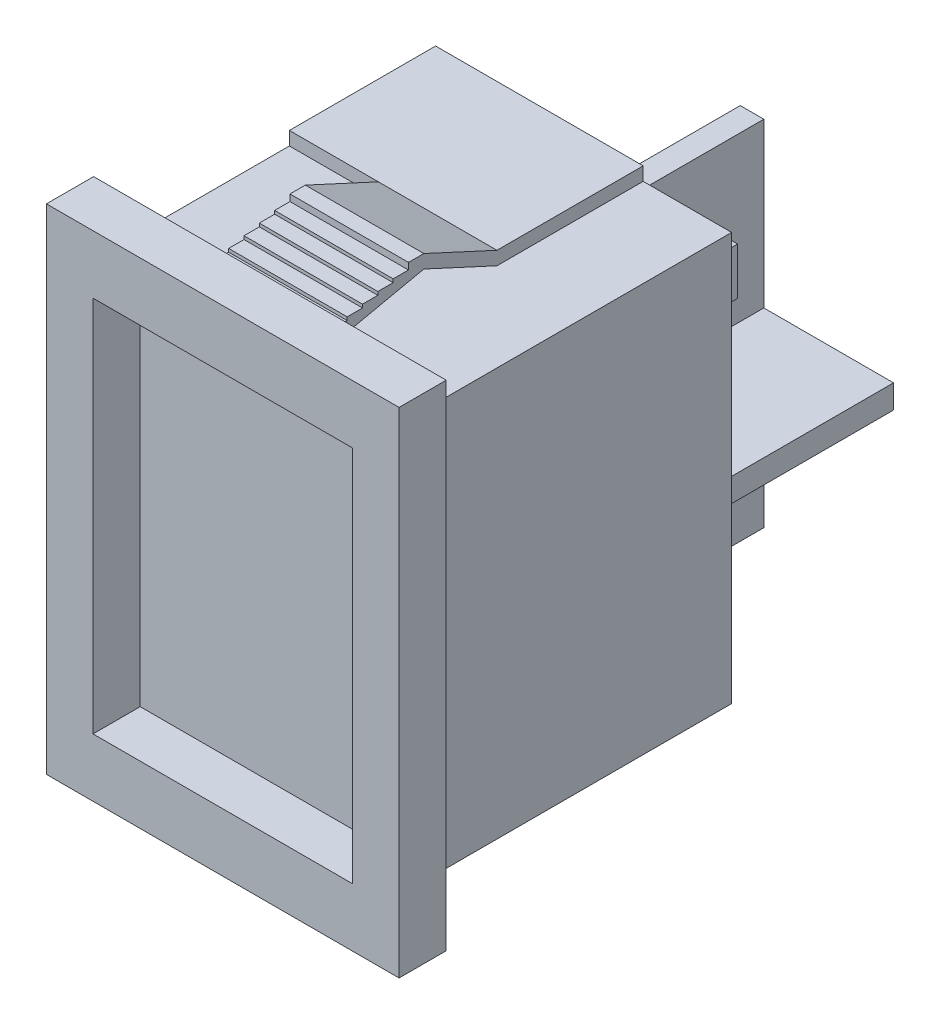
from build123d import *

# Parameters (mm, degrees)
SKETCH1_W                = 14.95
SKETCH1_H                = 20.95
SKETCH1_W_2              = 11
SKETCH1_H_2              = 16
BOSS_EXTRUDE1_DEPTH      = 2
SKETCH2_W                = 12.55
SKETCH2_H                = 17.3
BOSS_EXTRUDE2_DEPTH      = 13.3
SKETCH3_W                = 6.2
SKETCH3_H                = 18.44
BOSS_EXTRUDE3_DEPTH      = 8.8
BOSS_EXTRUDE4_DEPTH      = 2.525
BOSS_EXTRUDE4_DEPTH_BACK = 2.5
BOSS_EXTRUDE5_DEPTH      = 7.14
SKETCH6_W                = 2.5
SKETCH6_H                = 2
BOSS_EXTRUDE6_DEPTH      = 1


with BuildPart() as part:
    # Sketch1 → Boss-Extrude1 (new body)
    with BuildSketch(Plane.XY):
        Rectangle(SKETCH1_W, SKETCH1_H)
        Rectangle(SKETCH1_W_2, SKETCH1_H_2, mode=Mode.SUBTRACT)
    extrude(amount=BOSS_EXTRUDE1_DEPTH)

    # Sketch2 → Boss-Extrude2 (add)
    with BuildSketch(Plane(origin=(0, 0, 0), x_dir=(-1, 0, 0), z_dir=(0, 0, -1))):
        Rectangle(SKETCH2_W, SKETCH2_H)
    extrude(amount=BOSS_EXTRUDE2_DEPTH)

    # Sketch3 → Boss-Extrude3 (add)
    with BuildSketch(Plane.ZY.offset(6.275)):
        with Locations((-10.2, 0)):
            Rectangle(SKETCH3_W, SKETCH3_H)
    extrude(amount=-BOSS_EXTRUDE3_DEPTH)

    # Sketch4 → Boss-Extrude4 (add, two sides)
    with BuildSketch(Plane(origin=(0, 0, 0), x_dir=(0, 0, -1), z_dir=(1, 0, 0))) as boss_extrude4_sk:
        Polygon((7.1, -9.22), (4, -10.65), (3.35, -10.65), (3.35, -10.3705), (2.7, -10.3705), (2.7, -10.23075), (2.05, -10.23075), (2.05, -10.091), (1.4, -10.091), (1.4, -9.95125), (0.75, -9.95125), (0.75, -9.8115), (0, -9.8115), (0, -9.22), (4, -10.08), (7.1, -8.65), align=None)
        Polygon((7.1, 9.22), (7.1, 8.65), (4, 10.08), (0, 9.22), (0, 9.8115), (0.75, 9.8115), (0.75, 9.95125), (1.4, 9.95125), (1.4, 10.091), (2.05, 10.091), (2.05, 10.23075), (2.7, 10.23075), (2.7, 10.3705), (3.35, 10.3705), (3.35, 10.65), (4, 10.65), align=None)
    extrude(amount=BOSS_EXTRUDE4_DEPTH)
    extrude(boss_extrude4_sk.sketch, amount=-BOSS_EXTRUDE4_DEPTH_BACK)

    # Sketch5 → Boss-Extrude5 (add)
    with BuildSketch(Plane(origin=(0, 0, -13.3), x_dir=(-1, 0, 0), z_dir=(0, 0, -1))):
        Polygon((0.5, 6.35), (-0.5, 6.35), (-0.5, -0.58), (-6, -0.58), (-6, -1.58), (-0.5, -1.58), (-0.5, -8.65), (0.5, -8.65), (0.5, -1.58), (6, -1.58), (6, -0.58), (0.5, -0.58), align=None)
    extrude(amount=BOSS_EXTRUDE5_DEPTH)

    # Sketch6 → Boss-Extrude6 (add)
    with BuildSketch(Plane(origin=(0, 0, -13.3), x_dir=(-1, 0, 0), z_dir=(0, 0, -1))):
        with Locations((2.232930788, -2.58)):
            Rectangle(SKETCH6_W, SKETCH6_H)
        with Locations((2.232930788, -7.58)):
            Rectangle(SKETCH6_W, SKETCH6_H)
        with Locations((-2.232930788, -7.58)):
            Rectangle(SKETCH6_W, SKETCH6_H)
        with Locations((-2.232930788, -2.58)):
            Rectangle(SKETCH6_W, SKETCH6_H)
        with Locations((4.275, 6.35)):
            Rectangle(SKETCH6_W, SKETCH6_H)
        with Locations((-4.275, 6.35)):
            Rectangle(SKETCH6_W, SKETCH6_H)
    extrude(amount=BOSS_EXTRUDE6_DEPTH)


solid = part.part
